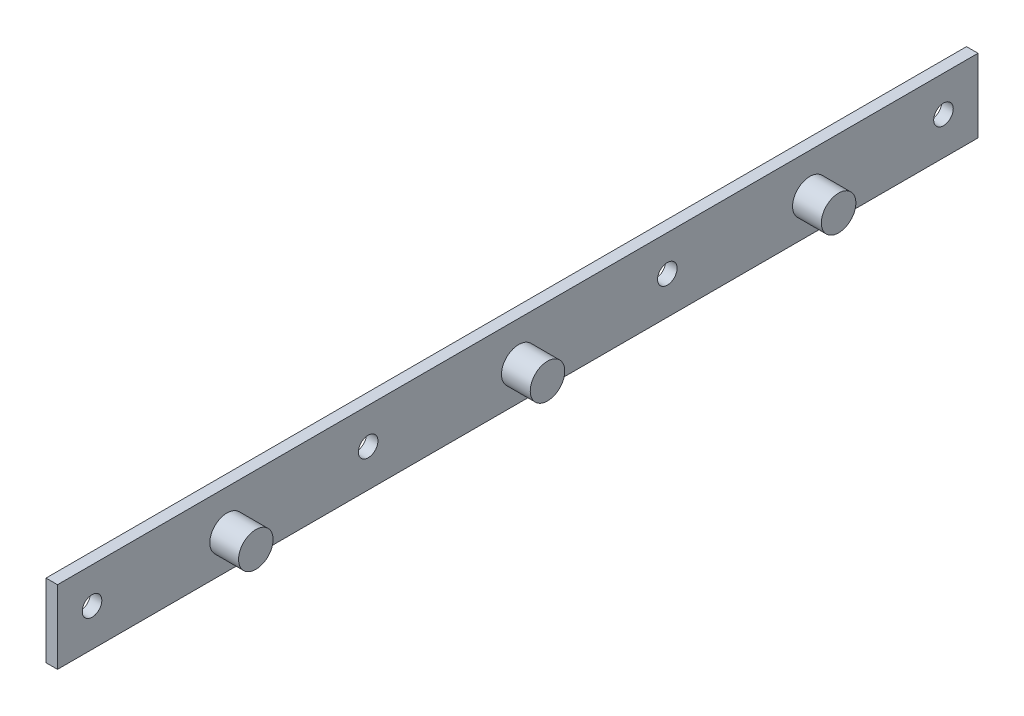
from build123d import *

# Parameters (mm, degrees)
ESBO_O1_W                = 160
ESBO_O1_H                = 12.75
ESBO_O1_R                = 1.7
RESSALTO_EXTRUS_O1_DEPTH = 2
ESBO_O2_R                = 3
RESSALTO_EXTRUS_O2_DEPTH = 5


with BuildPart() as part:
    # Esboço1 → Ressalto-extrusão1 (new body)
    with BuildSketch(Plane(origin=(0, 0, 0), x_dir=(0, 0, -1), z_dir=(1, 0, 0))):
        Rectangle(ESBO_O1_W, ESBO_O1_H)
        with Locations((-74, 0.175)):
            Circle(ESBO_O1_R, mode=Mode.SUBTRACT)
        with Locations((-26, 0.175)):
            Circle(ESBO_O1_R, mode=Mode.SUBTRACT)
        with Locations((26, 0.175)):
            Circle(ESBO_O1_R, mode=Mode.SUBTRACT)
        with Locations((74, 0.175)):
            Circle(ESBO_O1_R, mode=Mode.SUBTRACT)
    extrude(amount=RESSALTO_EXTRUS_O1_DEPTH)

    # Esboço2 → Ressalto-extrusão2 (add)
    with BuildSketch(Plane(origin=(2, 0, 0), x_dir=(0, 0, -1), z_dir=(1, 0, 0))):
        with Locations((0.17, -0.555)):
            Circle(ESBO_O2_R)
        with Locations((50.77, -0.555)):
            Circle(ESBO_O2_R)
        with Locations((-50.53, -0.555)):
            Circle(ESBO_O2_R)
    extrude(amount=RESSALTO_EXTRUS_O2_DEPTH)


solid = part.part
